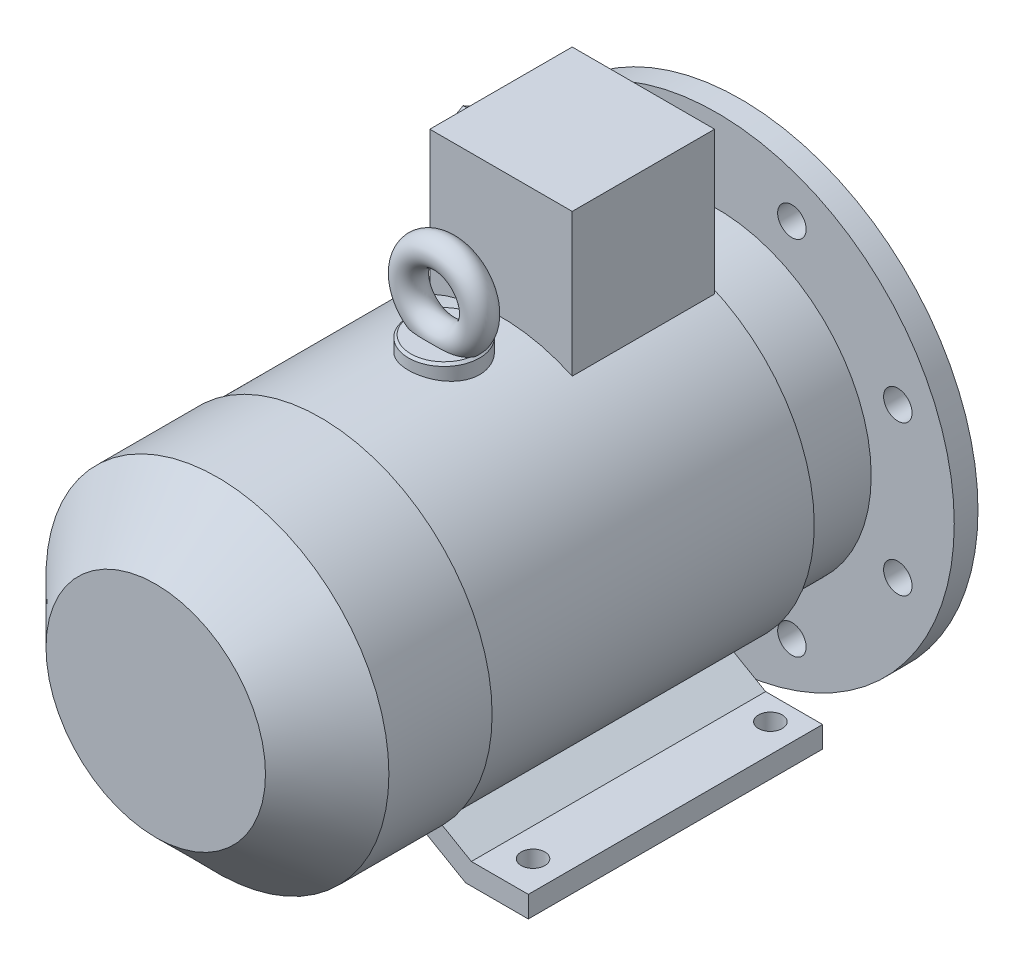
from build123d import *

# Parameters (mm, degrees)
SKETCH_1_R           = 11
EXTRUDE_1_DEPTH      = 50
SKETCH_2_W           = 6
SKETCH_2_H           = 6
EXTRUDE_2_DEPTH      = 0.1
EXTRUDE_2_DEPTH_BACK = 25
CHAMFER_1_SIZE       = 1
SKETCH_3_R           = 100
EXTRUDE_3_DEPTH      = 10
SKETCH_4_R           = 65
SKETCH_4_R_2         = 60
EXTRUDE_4_DEPTH      = 3.5
SKETCH_5_R           = 60
SKETCH_5_R_2         = 18
CUT_EXTRUDE_1_DEPTH  = 3.5
CHAMFER_2_SIZE       = 1
SKETCH_6_R           = 65
EXTRUDE_5_DEPTH      = 30
SKETCH_7_R           = 71
EXTRUDE_6_DEPTH      = 137
SKETCH_8_R           = 72.248091185
EXTRUDE_7_DEPTH      = 69.5
CHAMFER_3_SIZE       = 26
SKETCH_9_R           = 6
CUT_EXTRUDE_2_DEPTH  = 247.5
EXTRUDE_8_DEPTH      = 124
CUT_EXTRUDE_3_REACH  = 182
SKETCH_11_R          = 5
SKETCH_12_W          = 60
SKETCH_12_H          = 60
EXTRUDE_9_DEPTH      = 124.5
SKETCH_13_R          = 15
EXTRUDE_10_DEPTH     = 76.5
CHAMFER_4_SIZE       = 1
SKETCH_15_R          = 6
SKETCH_16_R          = 8
EXTRUDE_11_DEPTH     = 6
EXTRUDE_12_DEPTH     = 10
SKETCH_18_R          = 6
CUT_EXTRUDE_4_DEPTH  = 10


with BuildPart() as part:
    # Эскиз1 → Вытянуть1 (new body)
    with BuildSketch(Plane.XY):
        Circle(SKETCH_1_R)
    extrude(amount=EXTRUDE_1_DEPTH)

    # Эскиз2 → Вытянуть2 (add, two sides)
    with BuildSketch(Plane(origin=(0, 0, 0), x_dir=(-1, 0, 0), z_dir=(0, 0, -1))) as extrude_2_sk:
        with Locations((0, 10.5)):
            Rectangle(SKETCH_2_W, SKETCH_2_H)
    extrude(amount=EXTRUDE_2_DEPTH)
    extrude(extrude_2_sk.sketch, amount=-EXTRUDE_2_DEPTH_BACK)

    # Фаска1
    chamfer_1_edges = [part.edges().sort_by_distance(p)[0] for p in [
        (-6.633249581, -8.774964387, 0),
    ]]
    chamfer(chamfer_1_edges, length=CHAMFER_1_SIZE)

    # Эскиз3 → Вытянуть3 (add)
    with BuildSketch(Plane.XY.offset(50)):
        Circle(SKETCH_3_R)
    extrude(amount=EXTRUDE_3_DEPTH)

    # Эскиз4 → Вытянуть4 (add)
    with BuildSketch(Plane(origin=(0, 0, 50), x_dir=(-1, 0, 0), z_dir=(0, 0, -1))):
        with Locations(Location((0, 0, 0), (0, 0, 180))):  # turned: the seam where the file's is
            Circle(SKETCH_4_R)
        Circle(SKETCH_4_R_2, mode=Mode.SUBTRACT)
    extrude(amount=EXTRUDE_4_DEPTH)

    # Эскиз5 → Вырез-Вытянуть1 (cut)
    with BuildSketch(Plane(origin=(0, 0, 50), x_dir=(-1, 0, 0), z_dir=(0, 0, -1))):
        Circle(SKETCH_5_R)
        Circle(SKETCH_5_R_2, mode=Mode.SUBTRACT)
    extrude(amount=-CUT_EXTRUDE_1_DEPTH, mode=Mode.SUBTRACT)

    # Фаска2
    chamfer_2_edges = [part.edges().sort_by_distance(p)[0] for p in [
        (-65, 0, 46.5),
        (18, 0, 50),
    ]]
    chamfer(chamfer_2_edges, length=CHAMFER_2_SIZE)

    # Эскиз6 → Вытянуть5 (add)
    with BuildSketch(Plane.XY.offset(60)):
        Circle(SKETCH_6_R)
    extrude(amount=EXTRUDE_5_DEPTH)

    # Эскиз7 → Вытянуть6 (add)
    with BuildSketch(Plane.XY.offset(90)):
        Circle(SKETCH_7_R)
    extrude(amount=EXTRUDE_6_DEPTH)

    # Эскиз8 → Вытянуть7 (add)
    with BuildSketch(Plane.XY.offset(227)):
        Circle(SKETCH_8_R)
    extrude(amount=EXTRUDE_7_DEPTH)

    # Фаска3
    chamfer_3_edges = [part.edges().sort_by_distance(p)[0] for p in [
        (-72.248091185, 0, 296.5),
    ]]
    chamfer(chamfer_3_edges, length=CHAMFER_3_SIZE)

    # Эскиз9 → Вырез-Вытянуть2 (cut, through all)
    with BuildSketch(Plane(origin=(0, 0, 50), x_dir=(-1, 0, 0), z_dir=(0, 0, -1))):
        with Locations((-31.57138317, 76.220061432)):
            Circle(SKETCH_9_R)
        with Locations((31.57138317, 76.220061432)):
            Circle(SKETCH_9_R)
        with Locations((76.220061432, 31.57138317)):
            Circle(SKETCH_9_R)
        with Locations((76.220061432, -31.57138317)):
            Circle(SKETCH_9_R)
        with Locations((31.57138317, -76.220061432)):
            Circle(SKETCH_9_R)
        with Locations((-31.57138317, -76.220061432)):
            Circle(SKETCH_9_R)
        with Locations((-76.220061432, -31.57138317)):
            Circle(SKETCH_9_R)
        with Locations((-76.220061432, 31.57138317)):
            Circle(SKETCH_9_R)
    extrude(amount=-CUT_EXTRUDE_2_DEPTH, mode=Mode.SUBTRACT)

    # Эскиз10 → Вытянуть8 (add)
    with BuildSketch(Plane(origin=(0, 0, 90), x_dir=(-1, 0, 0), z_dir=(0, 0, -1))):
        Polygon((-74.5, -80), (-48.088457268, -80), (-11.515477308, -58.884580175), (-23.295059446, -55.293220248), (-50.5, -71), (-74.5, -71), align=None)
        Polygon((74.5, -71), (74.5, -80), (48.088457268, -80), (11.515477308, -58.884580175), (23.295059446, -55.293220248), (50.5, -71), align=None)
    extrude(amount=-EXTRUDE_8_DEPTH)

    # Эскиз11 → Вырез-Вытянуть3 (cut, up to next)
    with BuildSketch(Plane.XZ.offset(80), mode=Mode.PRIVATE) as cut_extrude_3_sk1:
        with Locations(Location((-62.5, 100, 0), (0, 0, 270))):  # turned: the seam where the file's is
            Circle(SKETCH_11_R)
    cut_extrude_3_tool1 = extrude(cut_extrude_3_sk1.sketch, amount=-CUT_EXTRUDE_3_REACH, mode=Mode.PRIVATE) & part.part
    add(cut_extrude_3_tool1.solids().sort_by_distance((-62.5, -80, 100))[0], mode=Mode.SUBTRACT)
    # Эскиз11 → Вырез-Вытянуть3 (cut, up to next)
    with BuildSketch(Plane.XZ.offset(80), mode=Mode.PRIVATE) as cut_extrude_3_sk2:
        with Locations(Location((62.5, 100, 0), (0, 0, 270))):  # turned: the seam where the file's is
            Circle(SKETCH_11_R)
    cut_extrude_3_tool2 = extrude(cut_extrude_3_sk2.sketch, amount=-CUT_EXTRUDE_3_REACH, mode=Mode.PRIVATE) & part.part
    add(cut_extrude_3_tool2.solids().sort_by_distance((62.5, -80, 100))[0], mode=Mode.SUBTRACT)
    # Эскиз11 → Вырез-Вытянуть3 (cut, up to next)
    with BuildSketch(Plane.XZ.offset(80), mode=Mode.PRIVATE) as cut_extrude_3_sk3:
        with Locations(Location((-62.5, 200, 0), (0, 0, 270))):  # turned: the seam where the file's is
            Circle(SKETCH_11_R)
    cut_extrude_3_tool3 = extrude(cut_extrude_3_sk3.sketch, amount=-CUT_EXTRUDE_3_REACH, mode=Mode.PRIVATE) & part.part
    add(cut_extrude_3_tool3.solids().sort_by_distance((-62.5, -80, 200))[0], mode=Mode.SUBTRACT)
    # Эскиз11 → Вырез-Вытянуть3 (cut, up to next)
    with BuildSketch(Plane.XZ.offset(80), mode=Mode.PRIVATE) as cut_extrude_3_sk4:
        with Locations(Location((62.5, 200, 0), (0, 0, 270))):  # turned: the seam where the file's is
            Circle(SKETCH_11_R)
    cut_extrude_3_tool4 = extrude(cut_extrude_3_sk4.sketch, amount=-CUT_EXTRUDE_3_REACH, mode=Mode.PRIVATE) & part.part
    add(cut_extrude_3_tool4.solids().sort_by_distance((62.5, -80, 200))[0], mode=Mode.SUBTRACT)

    # Эскиз12 → Вытянуть9 (add)
    with BuildSketch(Plane(origin=(0, 0, 0), x_dir=(1, 0, 0), z_dir=(0, 1, 0))):
        with Locations((0, -121)):
            Rectangle(SKETCH_12_W, SKETCH_12_H)
    extrude(amount=EXTRUDE_9_DEPTH)

    # Эскиз13 → Вытянуть10 (add)
    with BuildSketch(Plane(origin=(0, 0, 0), x_dir=(1, 0, 0), z_dir=(0, 1, 0))):
        with Locations(Location((0, -175, 0), (0, 0, 90))):  # turned: the seam where the file's is
            Circle(SKETCH_13_R)
    extrude(amount=EXTRUDE_10_DEPTH)

    # Фаска4
    chamfer_4_edges = [part.edges().sort_by_distance(p)[0] for p in [
        (0, 76.5, 190),
    ]]
    chamfer(chamfer_4_edges, length=CHAMFER_4_SIZE)

    # По траектории1: sweep along a path in Эскиз14
    with BuildLine(Plane.XY.offset(175)) as sweep_1_path:
        CenterArc((0, 91.5), 15, 0, 360)
    # Эскиз15 → По траектории1 (sweep)
    with BuildSketch(Plane(origin=(0, 0, 0), x_dir=(0, 0, -1), z_dir=(1, 0, 0))):
        with Locations((-175, 106.5)):
            Circle(SKETCH_15_R)
    sweep(path=sweep_1_path.line)

    # Эскиз16 → Вытянуть11 (add)
    with BuildSketch(Plane.ZY.offset(30)):
        with Locations(Location((121, 94.5, 0), (0, 0, 180))):  # turned: the seam where the file's is
            Circle(SKETCH_16_R)
    extrude(amount=EXTRUDE_11_DEPTH)

    # Эскиз17 → Вытянуть12 (add)
    with BuildSketch(Plane.ZY.offset(36)):
        Polygon((121, 110.088457268), (107.5, 102.294228634), (107.5, 86.705771366), (121, 78.911542732), (134.5, 86.705771366), (134.5, 102.294228634), align=None)
    extrude(amount=EXTRUDE_12_DEPTH)

    # Эскиз18 → Вырез-Вытянуть4 (cut)
    with BuildSketch(Plane.ZY.offset(46)):
        with Locations((121, 94.5)):
            Circle(SKETCH_18_R)
    extrude(amount=-CUT_EXTRUDE_4_DEPTH, mode=Mode.SUBTRACT)


solid = part.part
